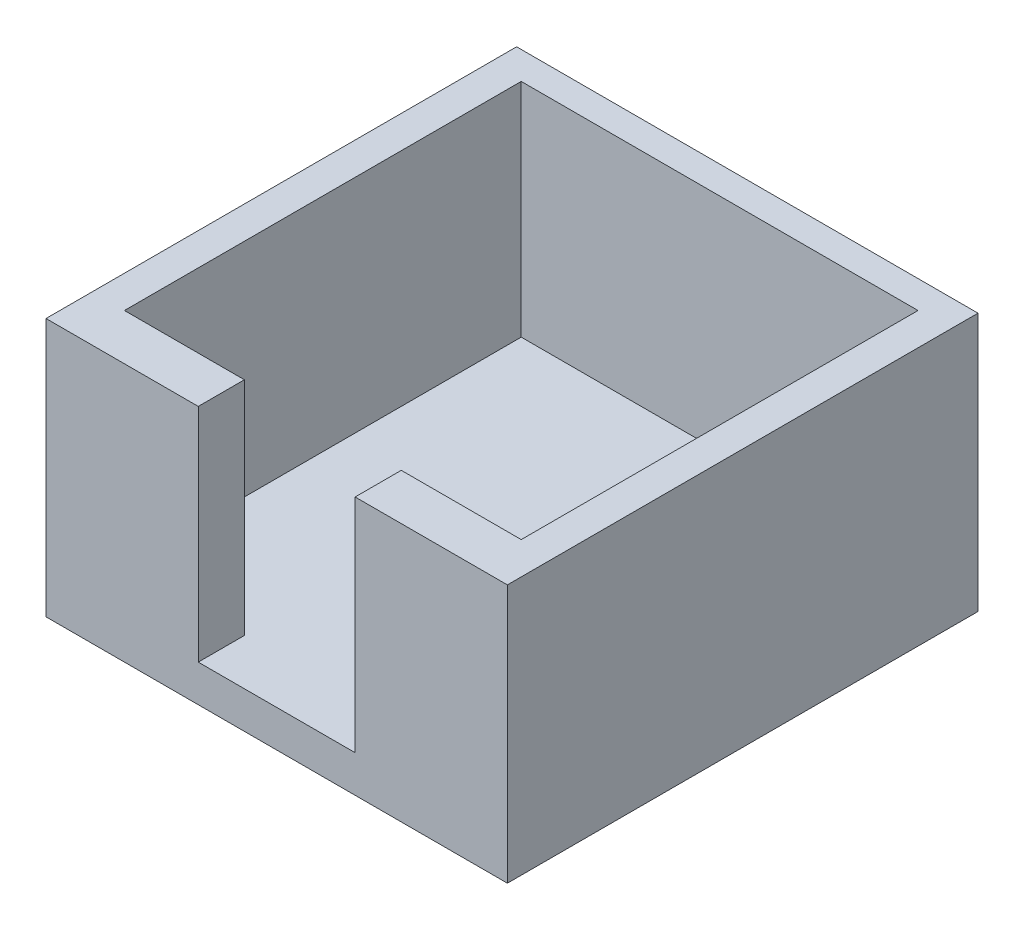
from build123d import *

# Parameters (mm, degrees)
SKETCH1_W           = 50
SKETCH1_H           = 51
BOSS_EXTRUDE1_DEPTH = 28
CUT_EXTRUDE1_DEPTH  = 24


with BuildPart() as part:
    # Sketch1 → Boss-Extrude1 (new body)
    with BuildSketch(Plane(origin=(0, 0, 0), x_dir=(1, 0, 0), z_dir=(0, 1, 0))):
        with Locations((25, 25.5)):
            Rectangle(SKETCH1_W, SKETCH1_H)
    extrude(amount=BOSS_EXTRUDE1_DEPTH)

    # Sketch2 → Cut-Extrude1 (cut)
    with BuildSketch(Plane(origin=(0, 28, 0), x_dir=(1, 0, 0), z_dir=(0, 1, 0))):
        Polygon((16.5, 5), (16.5, 0), (33.5, 0), (33.5, 5), (46.5, 5), (46.5, 48), (3.5, 48), (3.5, 5), align=None)
    extrude(amount=-CUT_EXTRUDE1_DEPTH, mode=Mode.SUBTRACT)


solid = part.part
